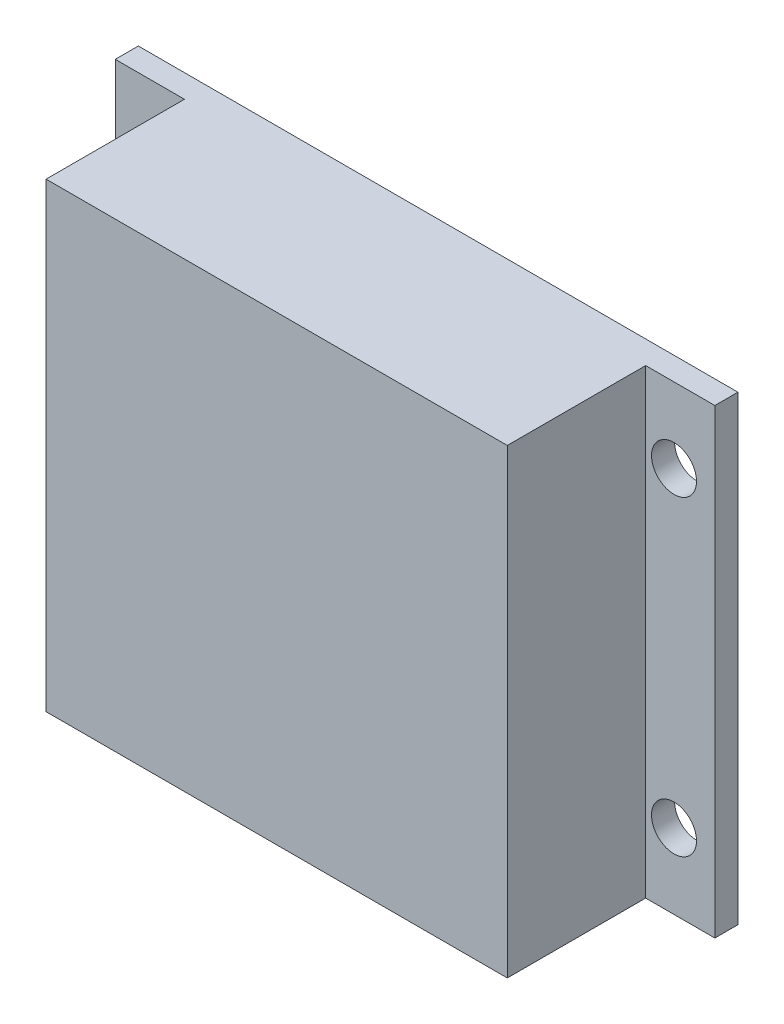
from build123d import *

# Parameters (mm, degrees)
SKETCH2_W               = 26
SKETCH2_H               = 20
BOSS_EXTRUDE1_DEPTH     = 1
SKETCH3_W               = 20
SKETCH3_H               = 20
BOSS_EXTRUDE2_DEPTH     = 6
SKETCH4_R               = 0.975
CUT_EXTRUDE1_DEPTH      = 2
MIRROR2_COPY_1_SKETCH_R = 0.975
MIRROR2_COPY_1_DEPTH    = 2


with BuildPart() as part:
    # Sketch2 → Boss-Extrude1 (new body)
    with BuildSketch(Plane.XY):
        Rectangle(SKETCH2_W, SKETCH2_H)
    extrude(amount=BOSS_EXTRUDE1_DEPTH)

    # Sketch3 → Boss-Extrude2 (add)
    with BuildSketch(Plane.XY.offset(1)):
        Rectangle(SKETCH3_W, SKETCH3_H)
    extrude(amount=BOSS_EXTRUDE2_DEPTH)

    # Sketch4 → Cut-Extrude1 (cut, through all)
    with BuildSketch(Plane.XY.offset(1)):
        with Locations((-11.23, 6.75)):
            Circle(SKETCH4_R)
    cut_extrude1 = extrude(amount=-CUT_EXTRUDE1_DEPTH, mode=Mode.SUBTRACT)

    # Mirror1: Cut-Extrude1 across plane
    add(cut_extrude1.mirror(Plane(origin=(0, 0, 0), x_dir=(0, 0, 1), z_dir=(1, 0, 0))), mode=Mode.SUBTRACT)

    # Mirror2: Cut-Extrude1 across plane
    add(cut_extrude1.mirror(Plane.ZX), mode=Mode.SUBTRACT)

    # Mirror2 copy 1 sketch → Mirror2 copy 1 (cut, through all)
    with BuildSketch(Plane(origin=(0, 0, 1), x_dir=(-1, 0, 0), z_dir=(0, 0, 1))):
        with Locations((-11.23, 6.75)):
            Circle(MIRROR2_COPY_1_SKETCH_R)
    extrude(amount=-MIRROR2_COPY_1_DEPTH, mode=Mode.SUBTRACT)


solid = part.part
